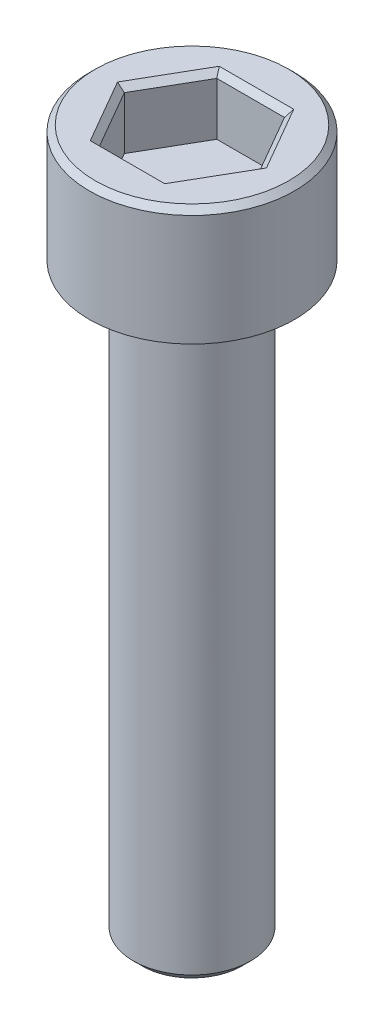
from build123d import *

# Parameters (mm, degrees)
SKETCH_1_R          = 3.5
EXTRUDE_1_DEPTH     = 4
SKETCH_2_R          = 2
EXTRUDE_2_DEPTH     = 20
CUT_EXTRUDE_1_DEPTH = 2
CHAMFER_1_SIZE      = 0.2
CHAMFER_2_SIZE      = 0.3


with BuildPart() as part:
    # 草图1 → 凸台-拉伸1 (new body)
    with BuildSketch(Plane(origin=(0, 0, 0), x_dir=(1, 0, 0), z_dir=(0, 1, 0))):
        Circle(SKETCH_1_R)
    extrude(amount=EXTRUDE_1_DEPTH)

    # 草图2 → 凸台-拉伸2 (add)
    with BuildSketch(Plane.XZ):
        Circle(SKETCH_2_R)
    extrude(amount=EXTRUDE_2_DEPTH)

    # 草图11 → 切除-拉伸1 (cut)
    with BuildSketch(Plane(origin=(0, 4, 0), x_dir=(1, 0, 0), z_dir=(0, 1, 0))):
        Polygon((1.154954177, 1.999853541), (-1.154446882, 2.000146427), (-2.309401058, 0.000292887), (-1.154954177, -1.999853541), (1.154446882, -2.000146427), (2.309401058, -0.000292887), align=None)
    extrude(amount=-CUT_EXTRUDE_1_DEPTH, mode=Mode.SUBTRACT)

    # 倒角1
    chamfer_1_edges = [part.edges().sort_by_distance(p)[0] for p in [
        (1.732177617, 4, -0.999780327),
        (0.000253647, 4, -1.999999984),
        (-1.73192397, 4, -1.000219657),
        (-1.732177617, 4, 0.999780327),
        (-0.000253647, 4, 1.999999984),
        (1.73192397, 4, 1.000219657),
        (-3.5, 4, 0),
    ]]
    chamfer(chamfer_1_edges, length=CHAMFER_1_SIZE)

    # 倒角2
    chamfer_2_edges = [part.edges().sort_by_distance(p)[0] for p in [
        (-2, -20, 0),
    ]]
    chamfer(chamfer_2_edges, length=CHAMFER_2_SIZE)


solid = part.part
